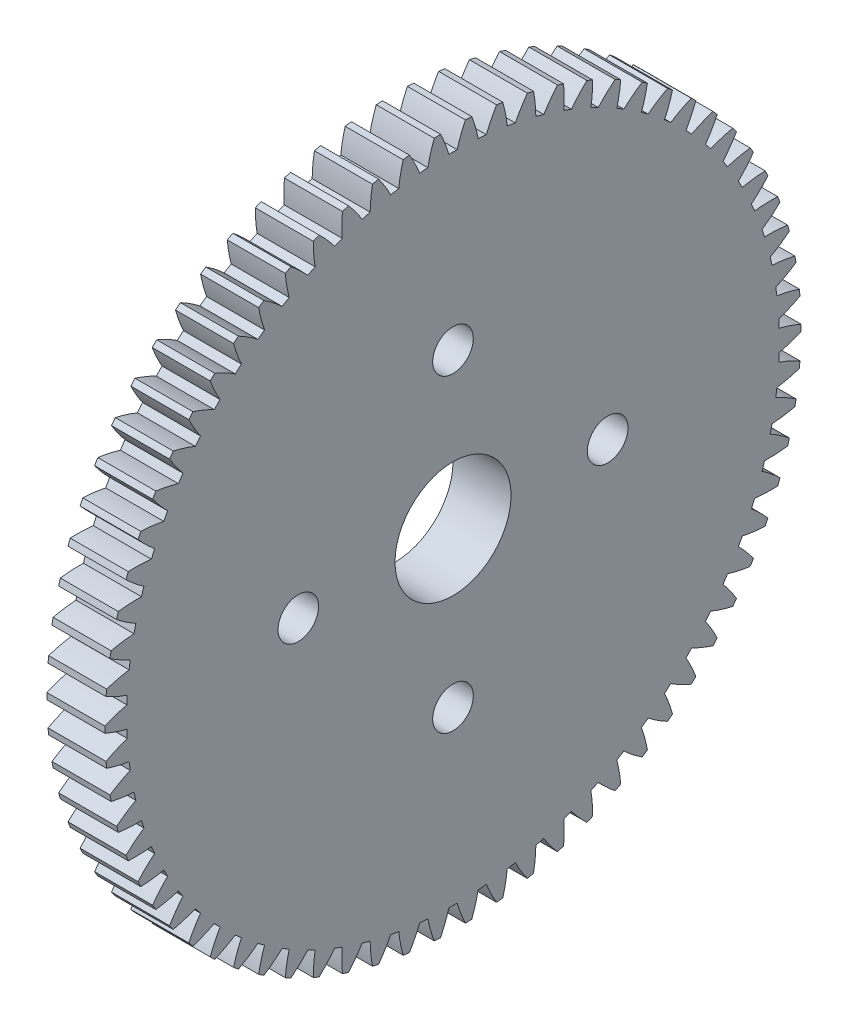
from build123d import *

# Parameters (mm, degrees)
BASPROSKE_W        = 3
BASPROSKE_H        = 18
TOOTHCUT_DEPTH     = 26.632011236
TEETHCUTS_COUNT    = 70
TEETHCUTS_ANGLE    = 354.857142857
BORSKE_R           = 3
BORE_DEPTH         = 8.0000508
SKETCH1_R          = 1.05
CUT_EXTRUDE1_DEPTH = 10
SKETCH3_R          = 14.5
SKETCH3_R_2        = 7.5
CUT_EXTRUDE3_DEPTH = 0.5


with BuildPart() as part:
    # BasProSke → Base-Revolve (revolve)
    with BuildSketch(Plane(origin=(0, 0, 0), x_dir=(1, 0, 0), z_dir=(0, 1, 0)), mode=Mode.PRIVATE) as base_revolve_sk:
        with Locations((1.5, 9)):
            Rectangle(BASPROSKE_W, BASPROSKE_H)
    revolve(base_revolve_sk.sketch.rotate(Axis((-10, 0, 0), (1, 0, 0)), 180), axis=Axis((-10, 0, 0), (1, 0, 0)))

    # TooCutSke → ToothCut (cut, through all)
    with BuildSketch(Plane(origin=(0, 0, 0), x_dir=(0, 0, -1), z_dir=(1, 0, 0))):
        with BuildLine():
            ThreePointArc((0.21220331, 16.872665639), (0, 16.874), (-0.21220331, 16.872665639))
            ThreePointArc((-0.21220331, 16.872665639), (-0.409386856, 17.452785162), (-0.656544674, 18.013439268))
            ThreePointArc((-0.656544674, 18.013439268), (0, 18.0254), (0.656544674, 18.013439268))
            ThreePointArc((0.656544674, 18.013439268), (0.409386856, 17.452785162), (0.21220331, 16.872665639))
        make_face()
    toothcut = extrude(amount=TOOTHCUT_DEPTH, mode=Mode.SUBTRACT)

    # TeethCuts: ToothCut ×70 about axis
    teethcuts_axis = Axis((-10, 0, 0), (1, 0, 0))
    for i in range(1, TEETHCUTS_COUNT):
        add(toothcut.rotate(teethcuts_axis, i * TEETHCUTS_ANGLE / (TEETHCUTS_COUNT - 1)), mode=Mode.SUBTRACT)

    # BorSke → Bore (cut, symmetric)
    with BuildSketch(Plane(origin=(0, 0, 0), x_dir=(0, 0, -1), z_dir=(1, 0, 0))):
        with Locations(Location((0, 0, 0), (0, 0, 180))):
            Circle(BORSKE_R)
    extrude(amount=BORE_DEPTH, both=True, mode=Mode.SUBTRACT)

    # Sketch1 → Cut-Extrude1 (cut)
    with BuildSketch(Plane(origin=(3, 0, 0), x_dir=(0, 0, -1), z_dir=(1, 0, 0))):
        with Locations((0, 8)):
            Circle(SKETCH1_R)
        with Locations((8, 0)):
            Circle(SKETCH1_R)
        with Locations((0, -8)):
            Circle(SKETCH1_R)
        with Locations((-8, 0)):
            Circle(SKETCH1_R)
    extrude(amount=-CUT_EXTRUDE1_DEPTH, mode=Mode.SUBTRACT)

    # Sketch3 → Cut-Extrude3 (cut)
    with BuildSketch(Plane.ZY):
        Circle(SKETCH3_R)
        Circle(SKETCH3_R_2, mode=Mode.SUBTRACT)
    extrude(amount=-CUT_EXTRUDE3_DEPTH, mode=Mode.SUBTRACT)


solid = part.part
